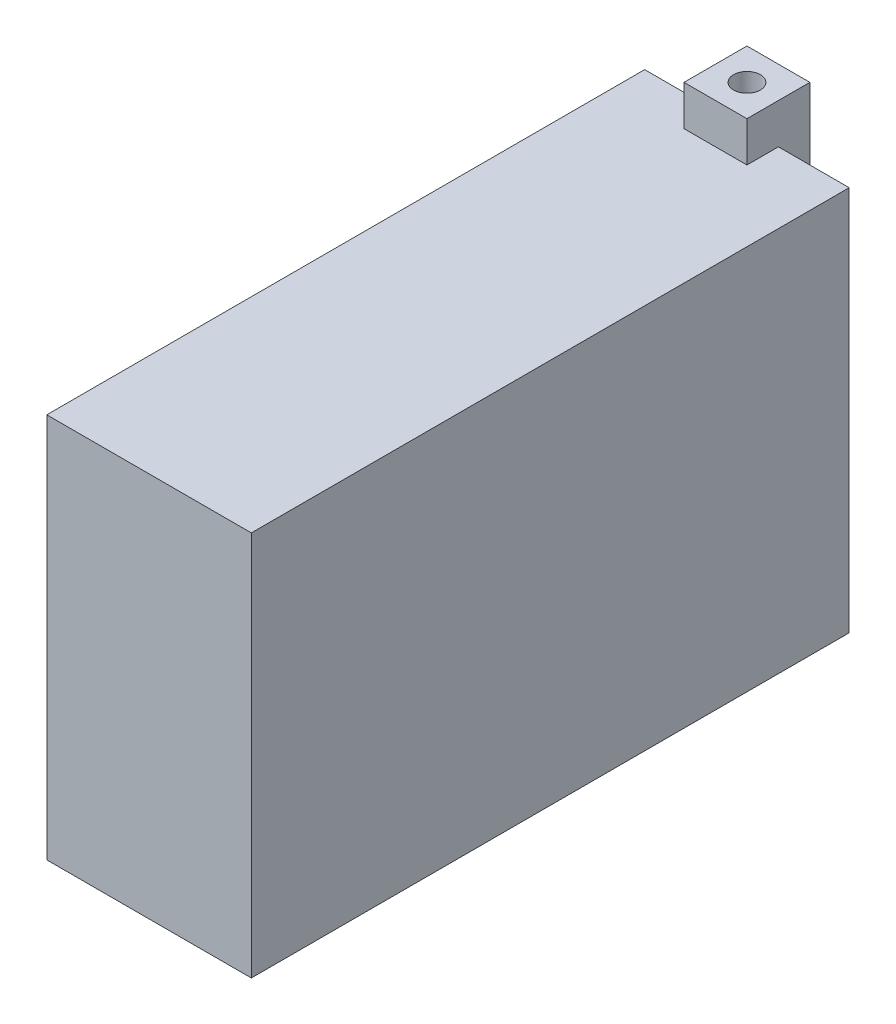
from build123d import *

# Parameters (mm, degrees)
SKETCH_1_W           = 380
SKETCH_1_H           = 245
EXTRUDE_1_DEPTH      = 65
EXTRUDE_1_DEPTH_BACK = 65
SKETCH_2_W           = 40
SKETCH_2_H           = 20
EXTRUDE_2_DEPTH      = 25.5
SKETCH_3_W           = 40
SKETCH_3_H           = 60
EXTRUDE_3_DEPTH      = 20
SKETCH_4_R           = 8.5
CUT_EXTRUDE_1_DEPTH  = 296


with BuildPart() as part:
    # Sketch 1 → Extrude 1 (new body, two sides)
    with BuildSketch(Plane(origin=(0, 0, 0), x_dir=(0, 0, -1), z_dir=(1, 0, 0))) as extrude_1_sk:
        Rectangle(SKETCH_1_W, SKETCH_1_H)
    extrude(amount=EXTRUDE_1_DEPTH)
    extrude(extrude_1_sk.sketch, amount=-EXTRUDE_1_DEPTH_BACK)

    # Sketch 2 → Extrude 2 (add)
    with BuildSketch(Plane(origin=(0, -122.5, -67.5), x_dir=(-1, 0, 0), z_dir=(0, 1, 0))):
        with Locations((0, -112.5)):
            Rectangle(SKETCH_2_W, SKETCH_2_H)
    extrude_2 = extrude(amount=-EXTRUDE_2_DEPTH)

    # Sketch 3 → Extrude 3 (add)
    with BuildSketch(Plane(origin=(0, 67.5, -190), x_dir=(1, 0, 0), z_dir=(0, 0, 1))):
        with Locations((0, -185.5)):
            Rectangle(SKETCH_3_W, SKETCH_3_H)
    extrude_3 = extrude(amount=-EXTRUDE_3_DEPTH)

    # Mirror 1: Extrude 2, Extrude 3 across plane
    add(extrude_2.mirror(Plane.ZX))
    add(extrude_3.mirror(Plane.ZX))

    # Sketch 4 → Cut-Extrude 1 (cut)
    with BuildSketch(Plane(origin=(0, -148, 0), x_dir=(-1, 0, 0), z_dir=(0, -1, 0))):
        with Locations((0, 190)):
            Circle(SKETCH_4_R)
    extrude(amount=-CUT_EXTRUDE_1_DEPTH, mode=Mode.SUBTRACT)


solid = part.part
